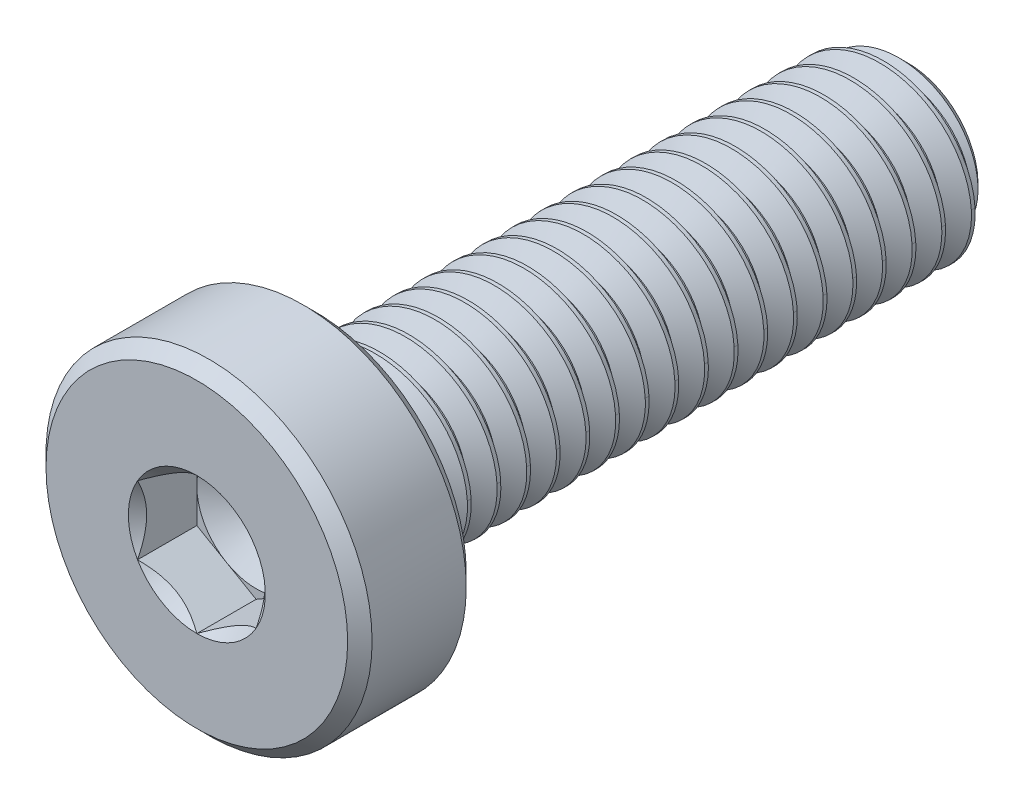
from build123d import *

# Parameters (mm, degrees)
CUT_EXTRUDE1_DEPTH     = 1
CUT_SWEEP1_PITCH       = 0.5
CUT_SWEEP1_HEIGHT      = 10.3125
CUT_SWEEP1_RADIUS      = 1.5
CUT_SWEEP1_START_ANGLE = 90


with BuildPart() as part:
    # Sketch2 → Revolve1 (revolve)
    with BuildSketch(Plane(origin=(0, 0, 0), x_dir=(0, 0, -1), z_dir=(1, 0, 0)), mode=Mode.PRIVATE) as revolve1_sk:
        with BuildLine():
            Line((-4.20625, 2.75), (-4, 2.54375))
            Line((-4, 2.54375), (-4, 1.65))
            ThreePointArc((-4, 1.65), (-3.956066017, 1.543933983), (-3.85, 1.5))
            Line((-3.85, 1.5), (5.675240474, 1.5))
            Line((5.675240474, 1.5), (6, 1.175240474))
            Line((6, 1.175240474), (6, 0))
            Line((6, 0), (-5, 0))
            Line((-5, 0), (-5, 1))
            Line((-5, 1), (-6, 1))
            Line((-6, 1), (-6, 2.54375))
            Line((-6, 2.54375), (-5.79375, 2.75))
            Line((-5.79375, 2.75), (-4.20625, 2.75))
        make_face()
    revolve(revolve1_sk.sketch.rotate(Axis((0, 0, 5), (0, 0, -1)), 90), axis=Axis((0, 0, 5), (0, 0, -1)))

    # Sketch3 → Cut-Extrude1 (cut)
    with BuildSketch(Plane.XY.offset(6)):
        Polygon((0, 1.154700538), (-1, 0.577350269), (-1, -0.577350269), (0, -1.154700538), (1, -0.577350269), (1, 0.577350269), align=None)
    extrude(amount=-CUT_EXTRUDE1_DEPTH, mode=Mode.SUBTRACT)

    # Cut-Extrude2 cone 1 section (through the dimple's axis) → Cut-Extrude2 (revolve, cut)
    with BuildSketch(Plane(origin=(0, 0, 6), x_dir=(0, -1, 0), z_dir=(1, 0, 0))):
        Polygon((0, 0), (1.154700538, 0), (0, 1.154700538), align=None)
    revolve(axis=Axis((0, 0, 6), (0, 0, -1)), mode=Mode.SUBTRACT)

    # Cut-Extrude5 cone 1 section (through the dimple's axis) → Cut-Extrude5 (revolve, cut)
    with BuildSketch(Plane(origin=(0, 0, 5), x_dir=(0, -1, 0), z_dir=(1, 0, 0))):
        Polygon((0, 0), (1, 0), (0, 0.577350269), align=None)
    revolve(axis=Axis((0, 0, 5), (0, 0, -1)), mode=Mode.SUBTRACT)

    # Cut-Sweep1: sweep along a helix
    with BuildLine() as cut_sweep1_path:
        add(Helix(CUT_SWEEP1_PITCH, CUT_SWEEP1_HEIGHT, CUT_SWEEP1_RADIUS, center=(0, 0, -6), direction=(0, 0, 1), mode=Mode.PRIVATE).rotate(Axis((0, 0, -6), (0, 0, 1)), CUT_SWEEP1_START_ANGLE))
    # Sketch8 → Cut-Sweep1 (sweep, cut)
    with BuildSketch(Plane(origin=(0, 0, 0), x_dir=(0, 0, -1), z_dir=(1, 0, 0))):
        Polygon((5.984375, 1.527063294), (6.453125, 1.527063294), (6.25, 1.175240474), (6.1875, 1.175240474), align=None)
    sweep(path=cut_sweep1_path.line, is_frenet=True, mode=Mode.SUBTRACT)

    # Sketch9 → Revolve2 (revolve)
    with BuildSketch(Plane(origin=(0, 0, 0), x_dir=(0, 0, -1), z_dir=(1, 0, 0)), mode=Mode.PRIVATE) as revolve2_sk:
        with BuildLine():
            Line((-4.34375, 0), (-4.34375, 1.65))
            Line((-4.34375, 1.65), (-4, 1.65))
            ThreePointArc((-4, 1.65), (-3.956066017, 1.543933983), (-3.85, 1.5))
            Line((-3.85, 1.5), (-3.5, 1.5))
            Line((-3.5, 1.5), (-2.633974596, 0))
            Line((-2.633974596, 0), (-4.34375, 0))
        make_face()
    revolve(revolve2_sk.sketch.rotate(Axis((0, 0, 2.633974596), (0, 0, 1)), 270), axis=Axis((0, 0, 2.633974596), (0, 0, 1)))


solid = part.part
